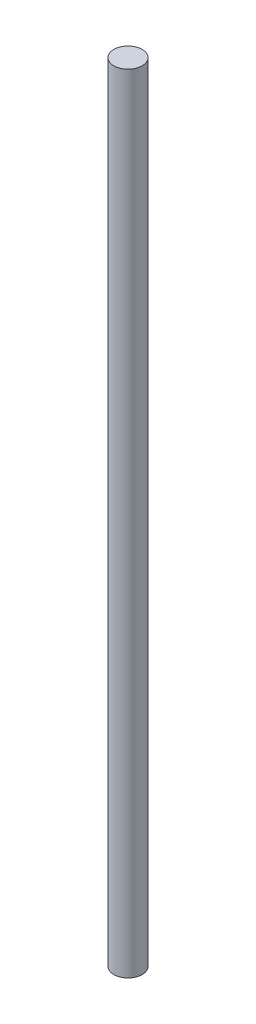
from build123d import *

# Parameters (mm, degrees)
SKETCH1_W = 4.7625
SKETCH1_H = 264


with BuildPart() as part:
    # Sketch1 → Revolve1 (revolve)
    with BuildSketch(Plane.XY):
        with Locations((2.38125, 132)):
            Rectangle(SKETCH1_W, SKETCH1_H)
    revolve(axis=Axis((4.7625, 264, 0), (0, -1, 0)))


solid = part.part
